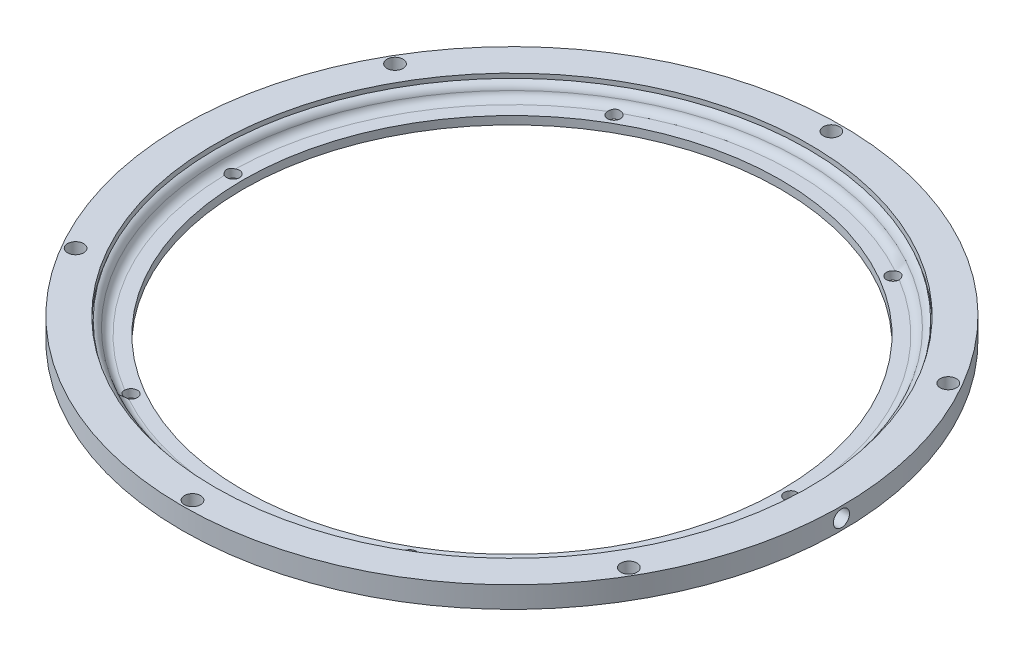
from build123d import *

# Parameters (mm, degrees)
CUT_EXTRUDE1_REACH            = 232.134
CUT_EXTRUDE1_END_MAJOR_RADIUS = 139.0875
CUT_EXTRUDE1_END_MINOR_RADIUS = 7.978855898
CIRPATTERN1_COUNT             = 6
CUT_EXTRUDE2_DEPTH            = 10
CIRPATTERN2_COUNT             = 6
SKETCH5_R                     = 3.175
CUT_EXTRUDE3_DEPTH            = 230.956573428
CIRPATTERN3_COUNT             = 6
SKETCH8_W                     = 9
SKETCH8_H                     = 10
REVOLVE3_ANGLE                = 5
SKETCH7_W                     = 14.5
SKETCH7_H                     = 3.96875
SKETCH9_R                     = 3.96875
CUT_EXTRUDE4_DEPTH            = 231.13423242
CIRPATTERN4_COUNT             = 6


with BuildPart() as part:
    # Sketch1 → Revolve2 (revolve)
    with BuildSketch(Plane.XY, mode=Mode.PRIVATE) as revolve2_sk:
        with BuildLine():
            Line((162.5, 12.2174), (162.5, 1.695399962))
            Line((162.5, 1.695399962), (149.5, 1.695399962))
            Line((149.5, 1.695399962), (149.5, 3.733424016))
            ThreePointArc((149.5, 3.733424016), (150.206637091, 7.634268042), (146.5, 9.040241574))
            Line((146.5, 9.040241574), (146.5, 12.2174))
            Line((146.5, 12.2174), (162.5, 12.2174))
        make_face()
        with BuildLine():
            Line((132.516, 0), (148, 0))
            Line((148, 0), (148, 3.047991585))
            ThreePointArc((148, 3.047991585), (144.579009367, 5.093311468), (146, 8.817193308))
            Line((146, 8.817193308), (146, 10.348503769))
            ThreePointArc((146, 10.348503769), (144.168282254, 9.12470487), (143.136921458, 7.178126191))
            ThreePointArc((143.136921458, 7.178126191), (141.661324986, 4.889407097), (139.0875, 4))
            Line((139.0875, 4), (132.516, 4))
            Line((132.516, 4), (132.516, 0))
        make_face()
    revolve(revolve2_sk.sketch.rotate(Axis((0, 8.550989641, 0), (0, -1, 0)), 90), axis=Axis((0, 8.550989641, 0), (0, -1, 0)))

    # Cut-Extrude1: up to this torus (the profile starts outside it)
    cut_extrude1_end = Plane(origin=(0, 8.168855898, 0), z_dir=(0, 1, 0)) * Torus(CUT_EXTRUDE1_END_MAJOR_RADIUS, CUT_EXTRUDE1_END_MINOR_RADIUS, mode=Mode.PRIVATE)
    # Sketch2 → Cut-Extrude1 (cut, up to the surface)
    with BuildSketch(Plane.XZ, mode=Mode.PRIVATE) as cut_extrude1_sk1:
        with BuildLine():
            ThreePointArc((75.01090718, -111.6598319), (116.494273215, -67.258), (134.205704598, -9.131435229))
            ThreePointArc((134.205704598, -9.131435229), (137.385386013, -6.356883356), (140.159937887, -9.536564771))
            ThreePointArc((140.159937887, -9.536564771), (121.662712825, -70.242), (78.3388763, -116.613784417))
            ThreePointArc((78.3388763, -116.613784417), (74.197915482, -115.800792718), (75.01090718, -111.6598319))
        make_face()
    cut_extrude1_tool1 = extrude(cut_extrude1_sk1.sketch, amount=-CUT_EXTRUDE1_REACH, mode=Mode.PRIVATE) - cut_extrude1_end
    cut_extrude1 = cut_extrude1_tool1.solids().sort_by_distance((120.543923, 0, -69.596066))[0]
    add(cut_extrude1, mode=Mode.SUBTRACT)

    # CirPattern1: Cut-Extrude1 ×6 about axis
    cirpattern1_axis = Axis((0, 0, 0), (0, 1, 0))
    for i in range(1, CIRPATTERN1_COUNT):
        add(cut_extrude1.rotate(cirpattern1_axis, i * 360 / CIRPATTERN1_COUNT), mode=Mode.SUBTRACT)

    # Sketch3 → Cut-Extrude2 (cut)
    with BuildSketch(Plane.XZ.offset(-1.695399962)):
        with BuildLine():
            Line((142.795745107, 73.277726353), (134.991399074, 68.77188507))
            ThreePointArc((134.991399074, 68.77188507), (151.5, 0), (134.991399074, -68.77188507))
            Line((134.991399074, -68.77188507), (142.795745107, -73.277726353))
            ThreePointArc((142.795745107, -73.277726353), (160.5, 0), (142.795745107, 73.277726353))
        make_face()
    cut_extrude2 = extrude(amount=-CUT_EXTRUDE2_DEPTH, mode=Mode.SUBTRACT)

    # CirPattern2: Cut-Extrude2 ×6 about axis
    cirpattern2_axis = Axis((0, 0, 0), (0, 1, 0))
    for i in range(1, CIRPATTERN2_COUNT):
        add(cut_extrude2.rotate(cirpattern2_axis, i * 360 / CIRPATTERN2_COUNT), mode=Mode.SUBTRACT)

    # Sketch5 → Cut-Extrude3 (cut, symmetric)
    with BuildSketch(Plane(origin=(0, 4, 0), x_dir=(-1, 0, 0), z_dir=(0, 1, 0))):
        with Locations(Location((-68.75, -119.07849302, 0), (0, 0, 90))):
            Circle(SKETCH5_R)
    cut_extrude3 = extrude(amount=CUT_EXTRUDE3_DEPTH, both=True, mode=Mode.SUBTRACT)

    # CirPattern3: Cut-Extrude3 ×6 about axis
    cirpattern3_axis = Axis((0, 0, 0), (0, 1, 0))
    for i in range(1, CIRPATTERN3_COUNT):
        add(cut_extrude3.rotate(cirpattern3_axis, i * 360 / CIRPATTERN3_COUNT), mode=Mode.SUBTRACT)

    # Sketch8 → Revolve3 (revolve, symmetric)
    with BuildSketch(Plane.XY) as revolve3_sk:
        with Locations((156, 6.695399962)):
            Rectangle(SKETCH8_W, SKETCH8_H)
    revolve(axis=Axis((0, 29.518266566, 0), (0, -1, 0)), revolution_arc=REVOLVE3_ANGLE / 2)
    revolve(revolve3_sk.sketch, axis=Axis((0, 29.518266566, 0), (0, 1, 0)), revolution_arc=REVOLVE3_ANGLE / 2)

    # Sketch7 → Cut-Revolve3 (revolve, cut)
    with BuildSketch(Plane.XY, mode=Mode.PRIVATE) as cut_revolve3_sk:
        with Locations((155.25, 8.940774981)):
            Rectangle(SKETCH7_W, SKETCH7_H)
    revolve(cut_revolve3_sk.sketch.rotate(Axis((162.5, 6.956399981, 0), (1, 0, 0)), 180), axis=Axis((162.5, 6.956399981, 0), (1, 0, 0)), mode=Mode.SUBTRACT)

    # Sketch9 → Cut-Extrude4 (cut, through all)
    with BuildSketch(Plane(origin=(0, 12.2174, 0), x_dir=(-1, 0, 0), z_dir=(0, 1, 0))):
        with Locations(Location((-136.399001096, -78.75, 0), (0, 0, 90))):
            Circle(SKETCH9_R)
    cut_extrude4 = extrude(amount=-CUT_EXTRUDE4_DEPTH, mode=Mode.SUBTRACT)

    # CirPattern4: Cut-Extrude4 ×6 about axis
    cirpattern4_axis = Axis((0, 0, 0), (0, 1, 0))
    for i in range(1, CIRPATTERN4_COUNT):
        add(cut_extrude4.rotate(cirpattern4_axis, i * 360 / CIRPATTERN4_COUNT), mode=Mode.SUBTRACT)


solid = part.part
